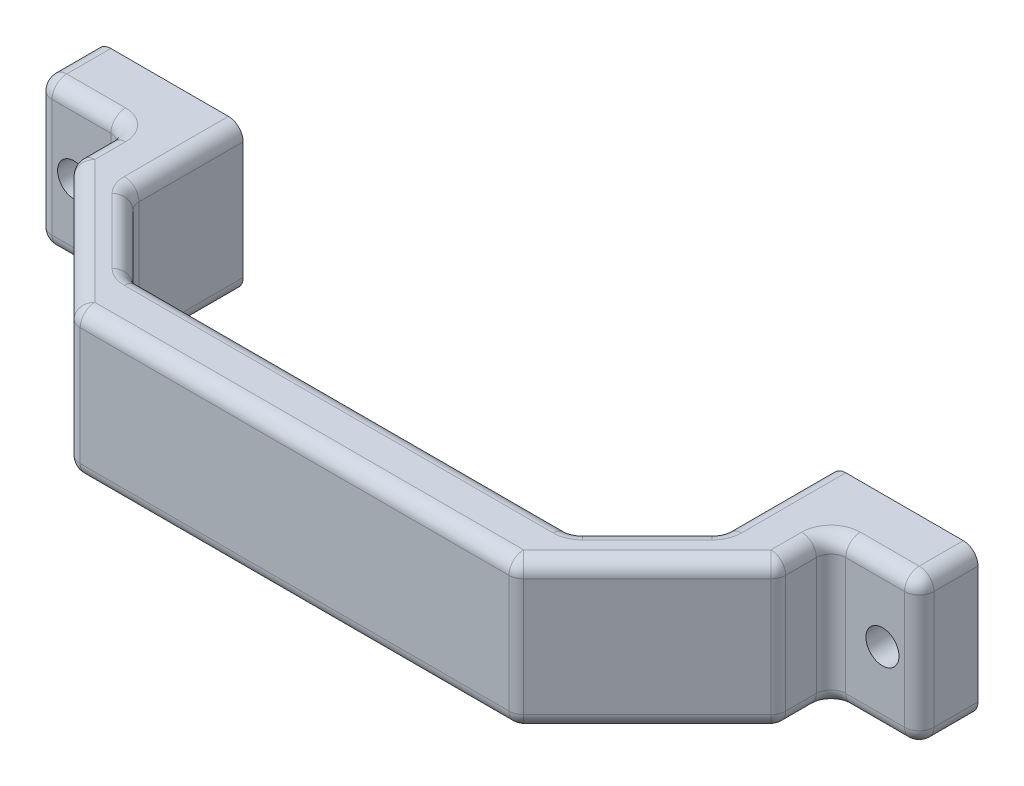
from build123d import *

# Parameters (mm, degrees)
SKETCH1_W             = 20
SKETCH1_H             = 20
SKETCH1_R             = 2.25
BOSS_EXTRUDE1_DEPTH   = 8
BOSS_EXTRUDE1_2_DEPTH = 8
BOSS_EXTRUDE2_DEPTH   = 20
FILLET2_R             = 2


with BuildPart() as part:
    # Sketch1 → Boss-Extrude1 (new body)
    with BuildSketch(Plane.XY):
        with Locations((-59.938271605, 0)):
            Rectangle(SKETCH1_W, SKETCH1_H)
        with Locations((-64.938271605, 0)):
            Circle(SKETCH1_R, mode=Mode.SUBTRACT)
    extrude(amount=BOSS_EXTRUDE1_DEPTH)



with BuildPart() as body_2:
    # Sketch1 → Boss-Extrude1 2 (new body)
    with BuildSketch(Plane.XY):
        with Locations((40.061728395, 0)):
            Rectangle(SKETCH1_W, SKETCH1_H)
        with Locations((45.061728395, 0)):
            Circle(SKETCH1_R, mode=Mode.SUBTRACT)
    extrude(amount=BOSS_EXTRUDE1_2_DEPTH)


with BuildPart() as part_1:
    add(part.part)

    add(body_2.part)  # Boss-Extrude2 merges body 2
    # Sketch2 → Boss-Extrude2 (add, through all)
    with BuildSketch(Plane.XZ.offset(10)):
        Polygon((-39.938271605, 25), (20.061728395, 25), (30.061728395, 15), (30.061728395, 8), (38.061728395, 8), (38.061728395, 15), (20.061728395, 33), (-39.938271605, 33), (-57.938271605, 15), (-57.938271605, 8), (-49.938271605, 8), (-49.938271605, 15), align=None)
    extrude(amount=-BOSS_EXTRUDE2_DEPTH)

    # Fillet2
    fillet2_edges = [part_1.edges().sort_by_distance(p)[0] for p in [
        (-69.938271605, 0, 8),
        (-63.938271605, -10, 8),
        (-63.938271605, 10, 8),
        (-44.938271605, 10, 20),
        (-39.938271605, 0, 25),
        (-49.938271605, 0, 15),
        (-57.938271605, 10, 11.5),
        (-57.938271605, 0, 8),
        (-48.938271605, 10, 24),
        (-57.938271605, 0, 15),
        (-9.938271605, 10, 33),
        (-39.938271605, 0, 33),
        (29.061728395, 10, 24),
        (20.061728395, 0, 33),
        (38.061728395, 10, 11.5),
        (38.061728395, 0, 15),
        (38.061728395, 0, 8),
        (30.061728395, 10, 7.5),
        (25.061728395, 10, 20),
        (30.061728395, 0, 15),
        (-9.938271605, 10, 25),
        (20.061728395, 0, 25),
        (-44.938271605, -10, 20),
        (-9.938271605, -10, 25),
        (25.061728395, -10, 20),
        (30.061728395, -10, 7.5),
        (38.061728395, -10, 11.5),
        (29.061728395, -10, 24),
        (-9.938271605, -10, 33),
        (-48.938271605, -10, 24),
        (-57.938271605, -10, 11.5),
        (44.061728395, -10, 8),
        (50.061728395, 0, 8),
        (44.061728395, 10, 8),
        (50.061728395, -10, 4),
        (50.061728395, 10, 4),
        (-49.938271605, -10, 7.5),
        (-69.938271605, -10, 4),
        (-69.938271605, 10, 4),
        (-49.938271605, 10, 7.5),
    ]]
    fillet(fillet2_edges, radius=FILLET2_R)


solid = part_1.part
